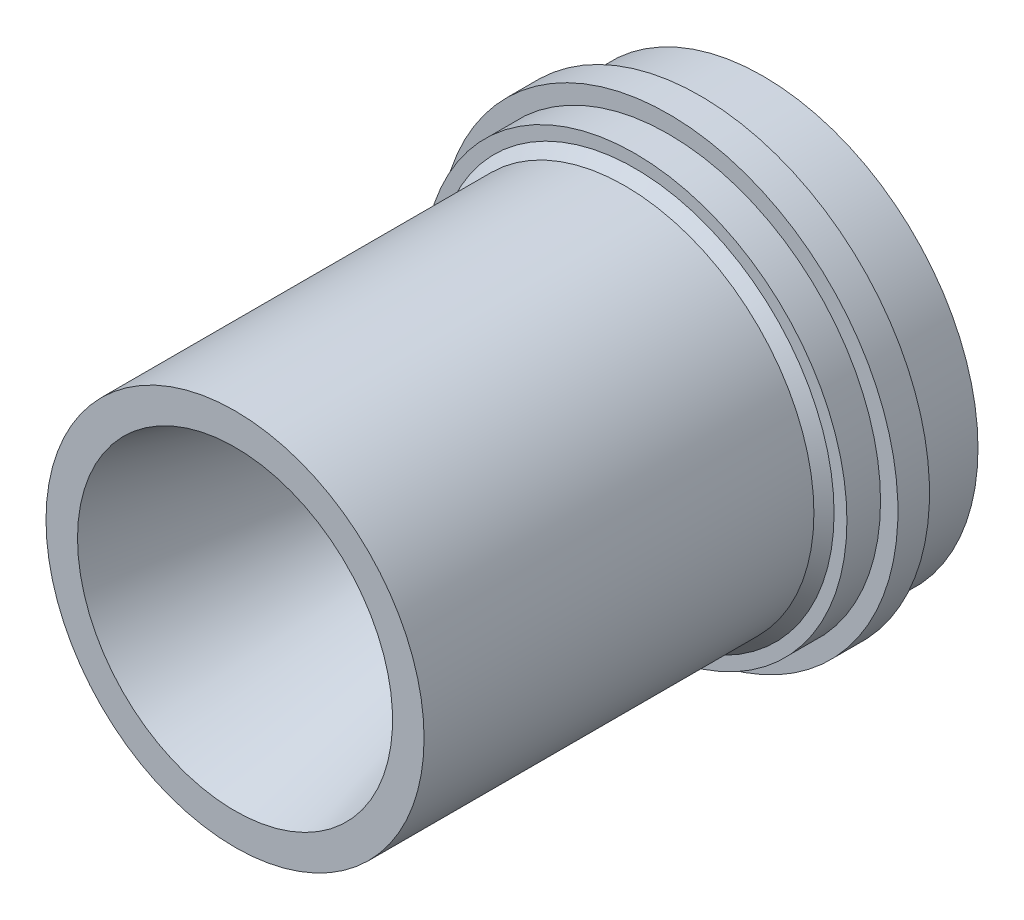
from build123d import *


with BuildPart() as part:
    # Sketch1 → Revolve1 (revolve)
    with BuildSketch(Plane(origin=(0, 0, 0), x_dir=(0, 0, -1), z_dir=(1, 0, 0))):
        with BuildLine():
            Line((-79.8322, 28.575), (-20.9042, 28.575))
            Line((-20.9042, 28.575), (-19.3802, 30.099))
            Line((-19.3802, 30.099), (-19.3802, 32.0421))
            Line((-19.3802, 32.0421), (-14.3002, 32.0421))
            Line((-14.3002, 32.0421), (-14.3002, 34.671))
            Line((-14.3002, 34.671), (-9.525, 34.671))
            Line((-9.525, 34.671), (-9.525, 32.4739))
            Line((-9.525, 32.4739), (0, 32.4739))
            Line((0, 32.4739), (0, 26.5811))
            Line((0, 26.5811), (-6.195945658, 15.84940732))
            ThreePointArc((-6.195945658, 15.84940732), (-11.462350599, 10.596653993), (-18.654516145, 8.6995))
            Line((-18.654516145, 8.6995), (-23.429716145, 8.6995))
            Line((-23.429716145, 8.6995), (-79.8322, 23.8125))
            Line((-79.8322, 23.8125), (-79.8322, 28.575))
        make_face()
    revolve(axis=Axis((0, 0, 0), (0, 0, 1)))


solid = part.part
